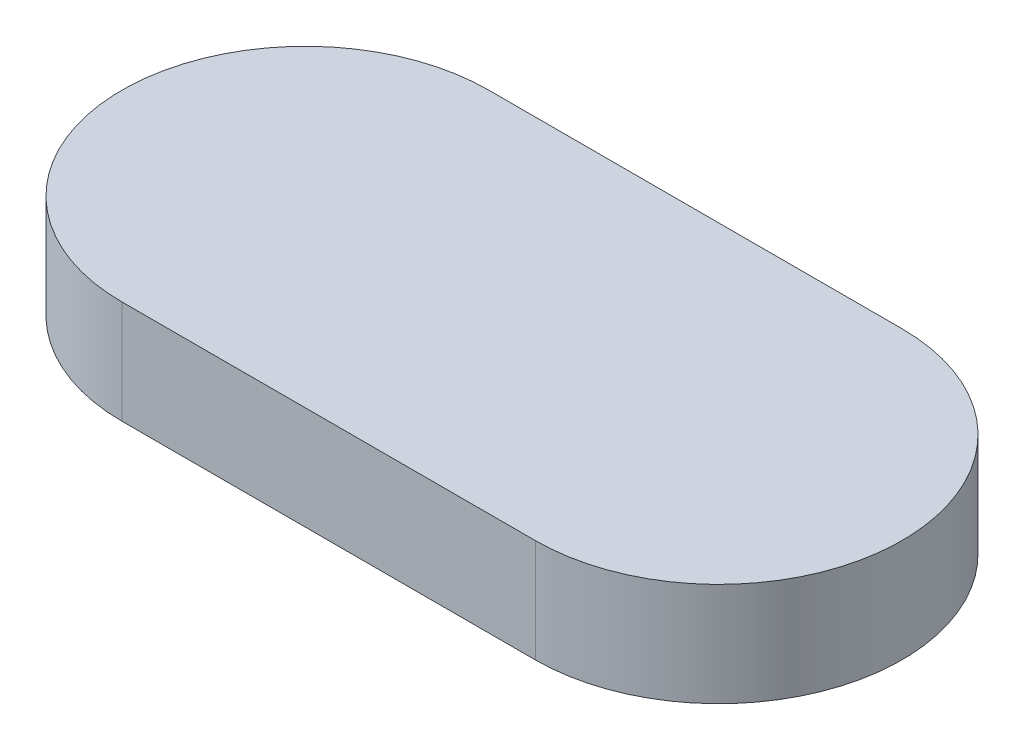
from build123d import *

# Parameters (mm, degrees)
AUFSATZ_LINEAR_AUSTRAGEN1_DEPTH = 5


with BuildPart() as part:
    # Skizze1 → Aufsatz-Linear austragen1 (new body)
    with BuildSketch(Plane(origin=(0, 0, 0), x_dir=(1, 0, 0), z_dir=(0, 1, 0))):
        with BuildLine():
            Line((-10, 8.875), (10, 8.875))
            ThreePointArc((10, 8.875), (18.875, 0), (10, -8.875))
            Line((10, -8.875), (-10, -8.875))
            ThreePointArc((-10, -8.875), (-18.875, 0), (-10, 8.875))
        make_face()
    extrude(amount=AUFSATZ_LINEAR_AUSTRAGEN1_DEPTH)


solid = part.part
